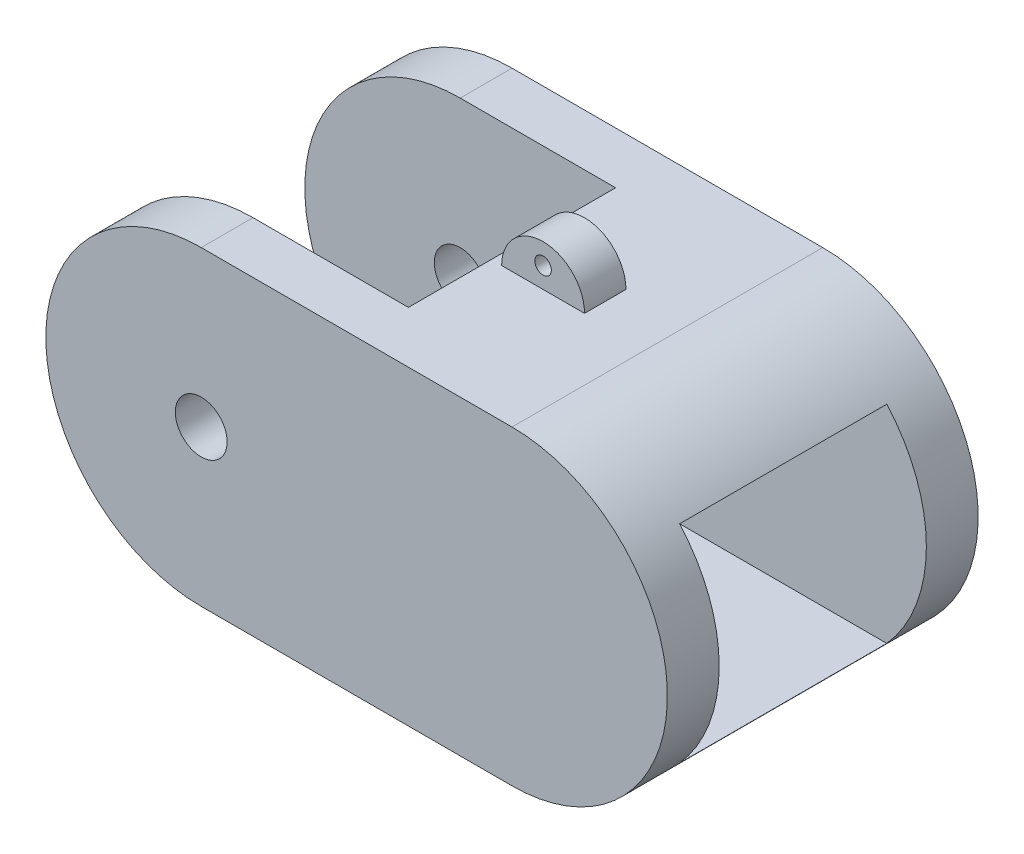
from build123d import *

# Parameters (mm, degrees)
SKETCH1_W           = 38.1
SKETCH1_H           = 19.05
BOSS_EXTRUDE1_DEPTH = 19.05
SKETCH2_R           = 1.5875
CUT_EXTRUDE2_DEPTH  = 19.05
SKETCH3_W           = 16.620070223
SKETCH3_H           = 12.7
CUT_EXTRUDE3_DEPTH  = 19.05
SKETCH4_W           = 12.7
SKETCH4_H           = 12.7
CUT_EXTRUDE4_DEPTH  = 50.8
SKETCH6_W           = 7.660570014
SKETCH6_H           = 3.81
BOSS_EXTRUDE2_DEPTH = 7.62
CUT_EXTRUDE6_DEPTH  = 19.05
SKETCH8_W           = 5.08
SKETCH8_H           = 2.54
BOSS_EXTRUDE3_DEPTH = 2.54
SKETCH9_R           = 0.508
CUT_EXTRUDE7_DEPTH  = 19.05
SKETCH10_W          = 9.525
SKETCH10_H          = 12.7
CUT_EXTRUDE8_DEPTH  = 3.81


with BuildPart() as part:
    # Sketch1 → Boss-Extrude1 (new body)
    with BuildSketch(Plane(origin=(0, 0, 0), x_dir=(1, 0, 0), z_dir=(0, 1, 0))):
        with Locations((-3.175, 0)):
            Rectangle(SKETCH1_W, SKETCH1_H)
    extrude(amount=BOSS_EXTRUDE1_DEPTH)

    # Sketch2 → Cut-Extrude2 (cut)
    with BuildSketch(Plane.XY.offset(9.525)):
        with Locations((-12.7, 9.525)):
            Circle(SKETCH2_R)
        with BuildLine():
            ThreePointArc((-12.7, 19.05), (-22.225, 9.525), (-12.7, 0))
            ThreePointArc((-12.7, 0), (-33.665146333, 9.525), (-12.7, 19.05))
        make_face()
        with BuildLine():
            ThreePointArc((6.35, 0), (15.875, 9.525), (6.35, 19.05))
            ThreePointArc((6.35, 19.05), (24.948138119, 9.525), (6.35, 0))
        make_face()
    extrude(amount=-CUT_EXTRUDE2_DEPTH, mode=Mode.SUBTRACT)

    # Sketch3 → Cut-Extrude3 (cut)
    with BuildSketch(Plane(origin=(0, 19.05, 0), x_dir=(1, 0, 0), z_dir=(0, 1, 0))):
        with Locations((-21.010035112, 0)):
            Rectangle(SKETCH3_W, SKETCH3_H)
    extrude(amount=-CUT_EXTRUDE3_DEPTH, mode=Mode.SUBTRACT)

    # Sketch4 → Cut-Extrude4 (cut)
    with BuildSketch(Plane(origin=(-15.875, 0, 0), x_dir=(0, 0, -1), z_dir=(1, 0, 0))):
        with Locations((0, 9.525)):
            Rectangle(SKETCH4_W, SKETCH4_H)
    extrude(amount=CUT_EXTRUDE4_DEPTH, mode=Mode.SUBTRACT)

    # Sketch6 → Boss-Extrude2 (add)
    with BuildSketch(Plane(origin=(0, 0, 0), x_dir=(1, 0, 0), z_dir=(0, 1, 0))):
        with Locations((-2.519714993, 0)):
            Rectangle(SKETCH6_W, SKETCH6_H)
    extrude(amount=-BOSS_EXTRUDE2_DEPTH)

    # Sketch7 → Cut-Extrude6 (cut)
    with BuildSketch(Plane.XY.offset(9.525)):
        with BuildLine():
            Line((-7.080935196, -3.131729905), (-6.858, 0))
            Line((-6.858, 0), (-6.858, -7.767816491))
            Line((-6.858, -7.767816491), (-14.771031914, -7.767816491))
            Line((-14.771031914, -7.767816491), (-14.771031914, 0))
            Line((-14.771031914, 0), (-9.975013633, 0))
            ThreePointArc((-9.975013633, 0), (-9.162678538, -1.206904896), (-8.794375076, -2.614335284))
            ThreePointArc((-8.794375076, -2.614335284), (-9.25025826, -3.647474967), (-10.163496252, -4.311706442))
            ThreePointArc((-10.163496252, -4.311706442), (-11.221462334, -3.861030674), (-11.89339597, -2.927807191))
            ThreePointArc((-11.89339597, -2.927807191), (-11.604147707, -2.390005207), (-10.996168015, -2.332941862))
            ThreePointArc((-10.996168015, -2.332941862), (-10.54556137, -1.577353268), (-11.301149964, -1.126746624))
            ThreePointArc((-11.301149964, -1.126746624), (-12.52752029, -1.573373178), (-13.044460874, -2.771802103))
            ThreePointArc((-13.044460874, -2.771802103), (-12.016160281, -5.071387383), (-9.595781192, -5.769427237))
            ThreePointArc((-9.595781192, -5.769427237), (-7.890109837, -4.877949662), (-7.080935196, -3.131729905))
        make_face()
        with BuildLine():
            Line((1.563031914, 0), (-3.232986367, 0))
            ThreePointArc((-3.232986367, 0), (-4.045321462, -1.206904896), (-4.413624924, -2.614335284))
            ThreePointArc((-4.413624924, -2.614335284), (-3.95774174, -3.647474967), (-3.044503748, -4.311706442))
            ThreePointArc((-3.044503748, -4.311706442), (-1.986537666, -3.861030674), (-1.31460403, -2.927807191))
            ThreePointArc((-1.31460403, -2.927807191), (-1.603852293, -2.390005207), (-2.211831985, -2.332941862))
            ThreePointArc((-2.211831985, -2.332941862), (-2.66243863, -1.577353268), (-1.906850036, -1.126746624))
            ThreePointArc((-1.906850036, -1.126746624), (-0.68047971, -1.573373178), (-0.163539126, -2.771802103))
            ThreePointArc((-0.163539126, -2.771802103), (-1.191839719, -5.071387383), (-3.612218808, -5.769427237))
            ThreePointArc((-3.612218808, -5.769427237), (-5.317890163, -4.877949662), (-6.127064804, -3.131729905))
            Line((-6.127064804, -3.131729905), (-6.35, 0))
            Line((-6.35, 0), (-6.35, -7.767816491))
            Line((-6.35, -7.767816491), (1.563031914, -7.767816491))
            Line((1.563031914, -7.767816491), (1.563031914, 0))
        make_face()
    extrude(amount=-CUT_EXTRUDE6_DEPTH, mode=Mode.SUBTRACT)

    # Sketch8 → Boss-Extrude3 (add)
    with BuildSketch(Plane(origin=(0, 19.05, 0), x_dir=(1, 0, 0), z_dir=(0, 1, 0))):
        Rectangle(SKETCH8_W, SKETCH8_H)
    extrude(amount=BOSS_EXTRUDE3_DEPTH)

    # Sketch9 → Cut-Extrude7 (cut)
    with BuildSketch(Plane.XY.offset(9.525)):
        with Locations((0, 20.32)):
            Circle(SKETCH9_R)
        with BuildLine():
            ThreePointArc((-2.54, 19.05), (0, 21.59), (2.54, 19.05))
            ThreePointArc((2.54, 19.05), (0, 23.383223271), (-2.54, 19.05))
        make_face()
    extrude(amount=-CUT_EXTRUDE7_DEPTH, mode=Mode.SUBTRACT)

    # Sketch10 → Cut-Extrude8 (cut)
    with BuildSketch(Plane(origin=(0, 19.05, 0), x_dir=(1, 0, 0), z_dir=(0, 1, 0))):
        with Locations((-7.9375, 0)):
            Rectangle(SKETCH10_W, SKETCH10_H)
    extrude(amount=-CUT_EXTRUDE8_DEPTH, mode=Mode.SUBTRACT)


solid = part.part
